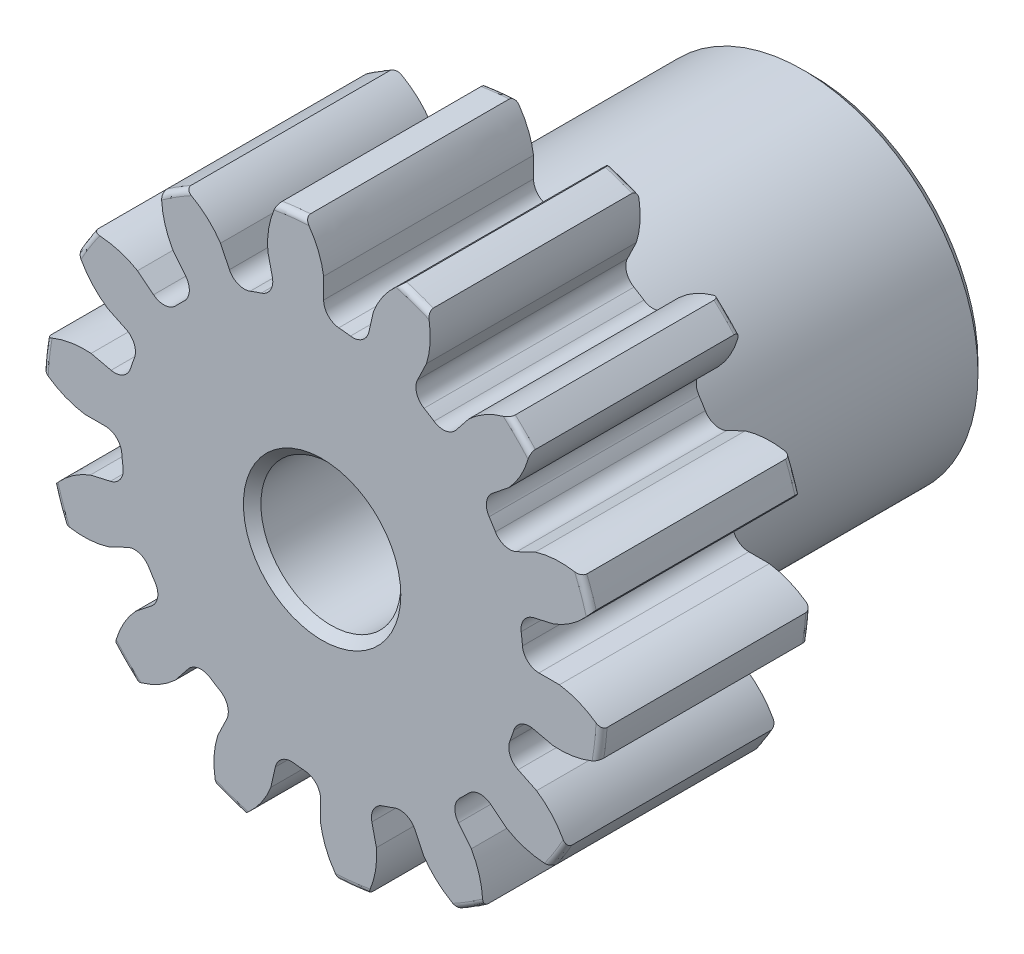
from build123d import *

# Parameters (mm, degrees)
SKETCH1_R                = 6.35
BOSS_EXTRUDE1_DEPTH      = 4.7625
SKETCH2_W                = 6.35
SKETCH2_H                = 3.96875
FILLET2_R                = 0.127
CUT_EXTRUDE1_DEPTH       = 12.1125
FILLET1_R                = 0.374474232
CIRPATTERN1_COUNT        = 14
FILLET1_OF_CIRPATTERN1_R = 0.374474232
SKETCH5_R                = 1.5875
CUT_EXTRUDE2_DEPTH       = 12.1125
CHAMFER1_SIZE            = 0.1984375


with BuildPart() as part:
    # Sketch1 → Boss-Extrude1 (new body)
    with BuildSketch(Plane.XY):
        Circle(SKETCH1_R)
    extrude(amount=-BOSS_EXTRUDE1_DEPTH)

    # Sketch2 → Revolve1 (revolve)
    with BuildSketch(Plane(origin=(0, 0, 0), x_dir=(0, 0, -1), z_dir=(1, 0, 0))):
        with Locations((7.9375, 1.984375)):
            Rectangle(SKETCH2_W, SKETCH2_H)
    revolve(axis=Axis((0, 0, -4.7625), (0, 0, -1)))

    # Fillet2
    fillet2_edges = [part.edges().sort_by_distance(p)[0] for p in [
        (-6.35, 0, 0),
        (-6.35, 0, -4.7625),
        (0, -3.96875, -4.7625),
    ]]
    fillet(fillet2_edges, radius=FILLET2_R)

    # Sketch4 → Cut-Extrude1 (cut, through all)
    with BuildSketch(Plane.XY):
        with BuildLine():
            Line((0.034788333, 5.385305702), (0.034788333, 4.561888785))
            ThreePointArc((0.034788333, 4.561888785), (0.510785529, 4.533336261), (0.981201974, 4.455253326))
            Line((0.981201974, 4.455253326), (1.164429897, 5.258025365))
            add(Edge.make_bspline(
                [(2.003924854, 6.24000827), (1.401095639, 5.864384587), (1.164429897, 5.258025365)],
                knots=[0, 0, 0, 1, 1, 1], degree=2))
            ThreePointArc((2.003924854, 6.24000827), (0.73380409, 6.512676069), (-0.56514638, 6.529473761))
            add(Edge.make_bspline(
                [(-0.56514638, 6.529473761), (-0.061015747, 6.029125364), (0.034788333, 5.385305702)],
                knots=[0, 0, 0, 1, 1, 1], degree=2))
        make_face()
    cut_extrude1 = extrude(amount=-CUT_EXTRUDE1_DEPTH, mode=Mode.SUBTRACT)

    # Fillet1
    fillet1_edges = [part.edges().sort_by_distance(p)[0] for p in [
        (0.981201974, 4.455253326, -2.38125),
        (0.034788333, 4.561888785, -2.38125),
    ]]
    fillet(fillet1_edges, radius=FILLET1_R)

    # CirPattern1: Cut-Extrude1 ×14 about axis
    cirpattern1_axis = Axis((0, 0, -4.7625), (0, 0, 1))
    for i in range(1, CIRPATTERN1_COUNT):
        add(cut_extrude1.rotate(cirpattern1_axis, i * 360 / CIRPATTERN1_COUNT), mode=Mode.SUBTRACT)

    # Fillet1 of CirPattern1
    fillet1_of_cirpattern1_edges = [part.edges().sort_by_distance(p)[0] for p in [
        (-1.04902954, 4.439772127, -2.38125),
        (-1.947986158, 4.125213866, -2.38125),
        (-2.871487889, 3.544939608, -2.38125),
        (-3.544938101, 2.871489749, -2.38125),
        (-4.125212844, 1.947988323, -2.38125),
        (-4.439771576, 1.04903187, -2.38125),
        (-4.561888803, -0.034785939, -2.38125),
        (-4.455253841, -0.981199636, -2.38125),
        (-4.095026737, -2.01067042, -2.38125),
        (-3.588318443, -2.817092521, -2.38125),
        (-2.817094404, -3.588316964, -2.38125),
        (-2.010672569, -4.095025682, -2.38125),
        (-0.981201974, -4.455253326, -2.38125),
        (-0.034788333, -4.561888785, -2.38125),
        (1.04902954, -4.439772127, -2.38125),
        (1.947986158, -4.125213866, -2.38125),
        (2.871487889, -3.544939608, -2.38125),
        (3.544938101, -2.871489749, -2.38125),
        (4.125212844, -1.947988323, -2.38125),
        (4.439771576, -1.04903187, -2.38125),
        (4.561888803, 0.034785939, -2.38125),
        (4.455253841, 0.981199636, -2.38125),
        (4.095026737, 2.01067042, -2.38125),
        (3.588318443, 2.817092521, -2.38125),
        (2.817094404, 3.588316964, -2.38125),
        (2.010672569, 4.095025682, -2.38125),
    ]]
    fillet(fillet1_of_cirpattern1_edges, radius=FILLET1_OF_CIRPATTERN1_R)

    # Sketch5 → Cut-Extrude2 (cut, through all)
    with BuildSketch(Plane.XY):
        Circle(SKETCH5_R)
    extrude(amount=-CUT_EXTRUDE2_DEPTH, mode=Mode.SUBTRACT)

    # Chamfer1
    chamfer1_edges = [part.edges().sort_by_distance(p)[0] for p in [
        (0, -3.96875, -11.1125),
        (-1.5875, 0, -11.1125),
        (-1.5875, 0, 0),
    ]]
    chamfer(chamfer1_edges, length=CHAMFER1_SIZE)


solid = part.part
